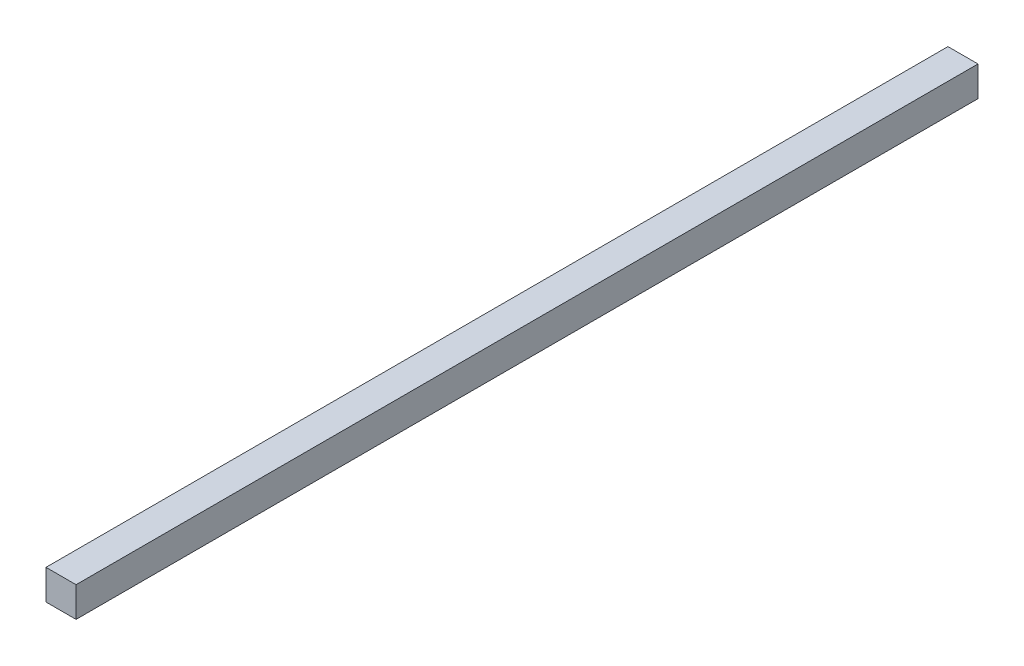
from build123d import *

# Parameters (mm, degrees)
ESQUISSE1_W        = 10
ESQUISSE1_H        = 10
BOSS_EXTRU_1_DEPTH = 300


with BuildPart() as part:
    # Esquisse1 → Boss.-Extru.1 (new body)
    with BuildSketch(Plane.XY):
        with Locations((-12.938723206, 0)):
            Rectangle(ESQUISSE1_W, ESQUISSE1_H)
    extrude(amount=BOSS_EXTRU_1_DEPTH)


solid = part.part
